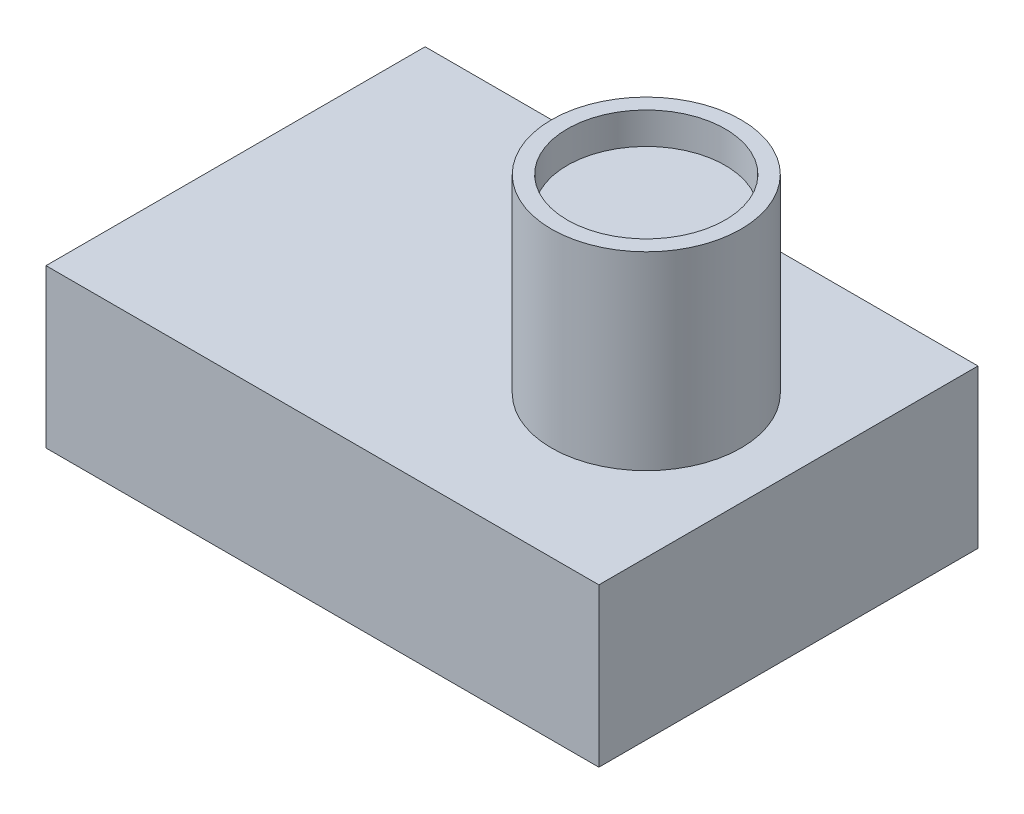
from build123d import *

# Parameters (mm, degrees)
SKETCH2_W           = 35
SKETCH2_H           = 24
BOSS_EXTRUDE1_DEPTH = 10
SKETCH3_R           = 6
BOSS_EXTRUDE2_DEPTH = 12
SKETCH4_R           = 5
CUT_EXTRUDE2_DEPTH  = 2


with BuildPart() as part:
    # Sketch2 → Boss-Extrude1 (new body)
    with BuildSketch(Plane(origin=(0, 0, 0), x_dir=(1, 0, 0), z_dir=(0, 1, 0))):
        Rectangle(SKETCH2_W, SKETCH2_H)
    extrude(amount=BOSS_EXTRUDE1_DEPTH)

    # Sketch3 → Boss-Extrude2 (add)
    with BuildSketch(Plane(origin=(0, 10, 0), x_dir=(1, 0, 0), z_dir=(0, 1, 0))):
        with Locations((8.5, 0)):
            Circle(SKETCH3_R)
    extrude(amount=BOSS_EXTRUDE2_DEPTH)

    # Sketch4 → Cut-Extrude2 (cut)
    with BuildSketch(Plane(origin=(0, 22, 0), x_dir=(1, 0, 0), z_dir=(0, 1, 0))):
        with Locations((8.5, 0)):
            Circle(SKETCH4_R)
    extrude(amount=-CUT_EXTRUDE2_DEPTH, mode=Mode.SUBTRACT)


solid = part.part
